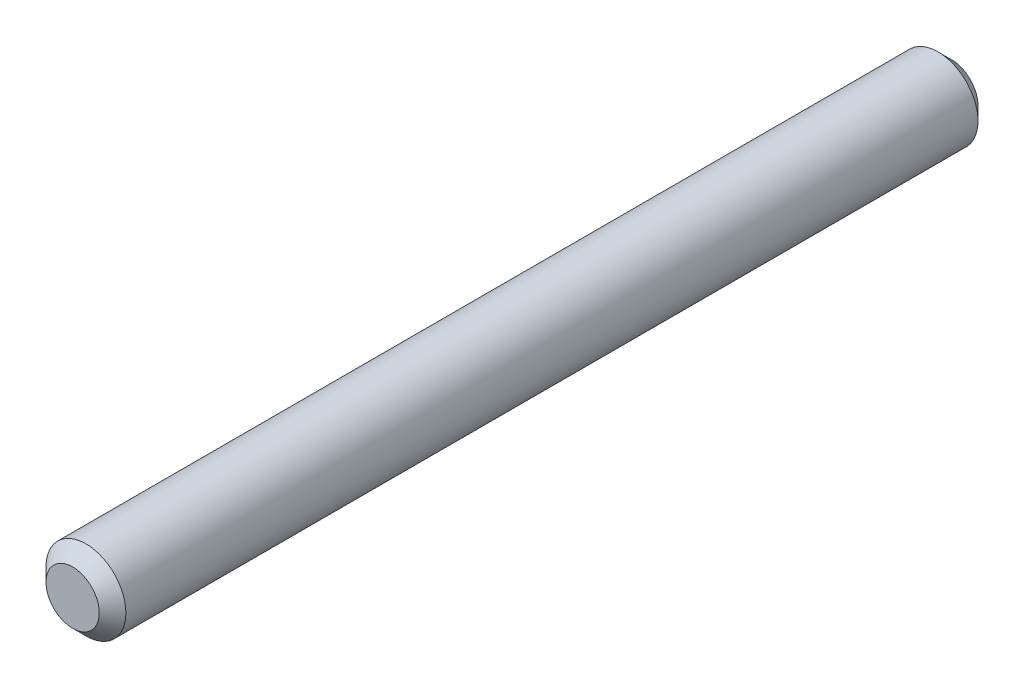
from build123d import *

# Parameters (mm, degrees)
SZKIC1_R                    = 3
DODANIE_WYCI_GNI_CIE1_DEPTH = 33
SFAZOWANIE1_SIZE            = 1


with BuildPart() as part:
    # Szkic1 → Dodanie-wyciągnięcie1 (new, symmetric)
    with BuildSketch(Plane.XY):
        Circle(SZKIC1_R)
    extrude(amount=DODANIE_WYCI_GNI_CIE1_DEPTH, both=True)

    # Sfazowanie1
    sfazowanie1_edges = [part.edges().sort_by_distance(p)[0] for p in [
        (-3, 0, -33),
        (-3, 0, 33),
    ]]
    chamfer(sfazowanie1_edges, length=SFAZOWANIE1_SIZE)


solid = part.part
